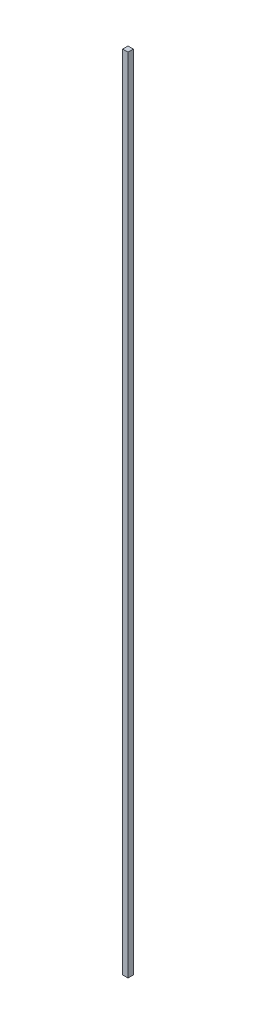
from build123d import *

# Parameters (mm, degrees)
SKETCH1_W           = 10
SKETCH1_H           = 10
BOSS_EXTRUDE1_DEPTH = 1500


with BuildPart() as part:
    # Sketch1 → Boss-Extrude1 (new body)
    with BuildSketch(Plane(origin=(0, 0, 0), x_dir=(1, 0, 0), z_dir=(0, 1, 0))):
        Rectangle(SKETCH1_W, SKETCH1_H)
    extrude(amount=BOSS_EXTRUDE1_DEPTH)


solid = part.part
